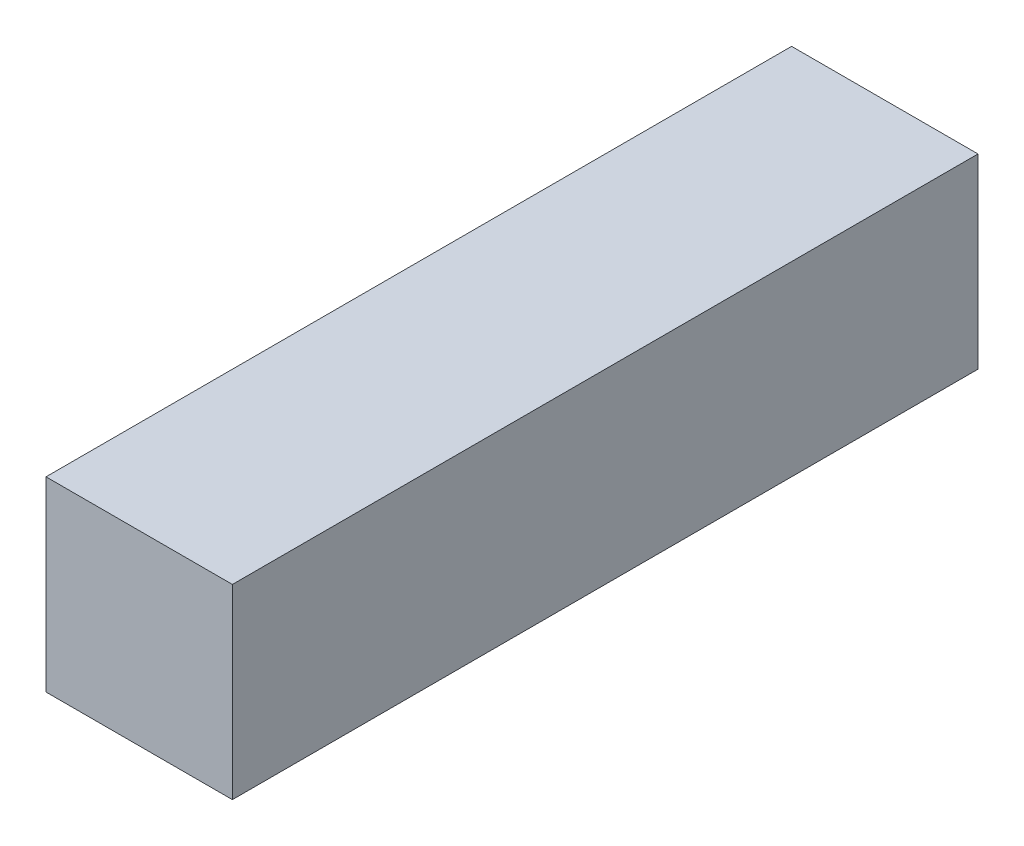
from build123d import *

# Parameters (mm, degrees)
SKETCH2_W           = 3
SKETCH2_H           = 3
BOSS_EXTRUDE1_DEPTH = 12


with BuildPart() as part:
    # Sketch2 → Boss-Extrude1 (new body)
    with BuildSketch(Plane.XY):
        with Locations((1.5, -1.5)):
            Rectangle(SKETCH2_W, SKETCH2_H)
    extrude(amount=BOSS_EXTRUDE1_DEPTH)


solid = part.part
